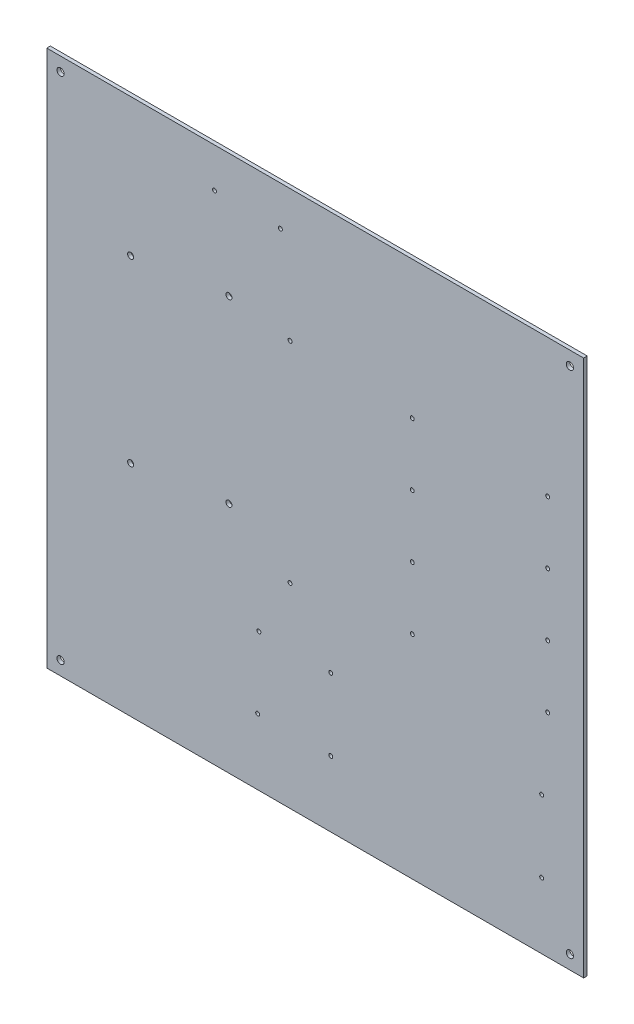
from build123d import *

# Parameters (mm, degrees)
SCHIZZO1_W                   = 448
SCHIZZO1_H                   = 448
SCHIZZO1_R                   = 3
SCHIZZO1_R_2                 = 1.65
SCHIZZO1_R_3                 = 2.5
ESTRUSIONE_ESTRUSIONE1_DEPTH = 3


with BuildPart() as part:
    # Schizzo1 → Estrusione-Estrusione1 (new body)
    with BuildSketch(Plane.XY):
        with Locations((224, 224)):
            Rectangle(SCHIZZO1_W, SCHIZZO1_H)
        with Locations((11.5, 436.5)):
            Circle(SCHIZZO1_R, mode=Mode.SUBTRACT)
        with Locations((436.5, 436.5)):
            Circle(SCHIZZO1_R, mode=Mode.SUBTRACT)
        with Locations((11.5, 11.5)):
            Circle(SCHIZZO1_R, mode=Mode.SUBTRACT)
        with Locations((436.5, 11.5)):
            Circle(SCHIZZO1_R, mode=Mode.SUBTRACT)
        with Locations((418, 177)):
            Circle(SCHIZZO1_R_2, mode=Mode.SUBTRACT)
        with Locations((305, 177)):
            Circle(SCHIZZO1_R_2, mode=Mode.SUBTRACT)
        with Locations((418, 229)):
            Circle(SCHIZZO1_R_2, mode=Mode.SUBTRACT)
        with Locations((305, 229)):
            Circle(SCHIZZO1_R_2, mode=Mode.SUBTRACT)
        with Locations((418, 281)):
            Circle(SCHIZZO1_R_2, mode=Mode.SUBTRACT)
        with Locations((305, 281)):
            Circle(SCHIZZO1_R_2, mode=Mode.SUBTRACT)
        with Locations((418, 333)):
            Circle(SCHIZZO1_R_2, mode=Mode.SUBTRACT)
        with Locations((305, 333)):
            Circle(SCHIZZO1_R_2, mode=Mode.SUBTRACT)
        with Locations((140, 415)):
            Circle(SCHIZZO1_R_2, mode=Mode.SUBTRACT)
        with Locations((195, 415)):
            Circle(SCHIZZO1_R_2, mode=Mode.SUBTRACT)
        with Locations((70, 333)):
            Circle(SCHIZZO1_R_3, mode=Mode.SUBTRACT)
        with Locations((70, 183)):
            Circle(SCHIZZO1_R_3, mode=Mode.SUBTRACT)
        with Locations((237, 55)):
            Circle(SCHIZZO1_R_2, mode=Mode.SUBTRACT)
        with Locations((237, 115)):
            Circle(SCHIZZO1_R_2, mode=Mode.SUBTRACT)
        with Locations((413, 115)):
            Circle(SCHIZZO1_R_2, mode=Mode.SUBTRACT)
        with Locations((413, 55)):
            Circle(SCHIZZO1_R_2, mode=Mode.SUBTRACT)
        with Locations((152, 344.76958941)):
            Circle(SCHIZZO1_R_3, mode=Mode.SUBTRACT)
        with Locations((152, 194.76958941)):
            Circle(SCHIZZO1_R_3, mode=Mode.SUBTRACT)
        with Locations((203, 338)):
            Circle(SCHIZZO1_R_2, mode=Mode.SUBTRACT)
        with Locations((203, 163)):
            Circle(SCHIZZO1_R_2, mode=Mode.SUBTRACT)
        with Locations((177, 115)):
            Circle(SCHIZZO1_R_2, mode=Mode.SUBTRACT)
        with Locations((176, 55)):
            Circle(SCHIZZO1_R_2, mode=Mode.SUBTRACT)
    extrude(amount=-ESTRUSIONE_ESTRUSIONE1_DEPTH)


solid = part.part
